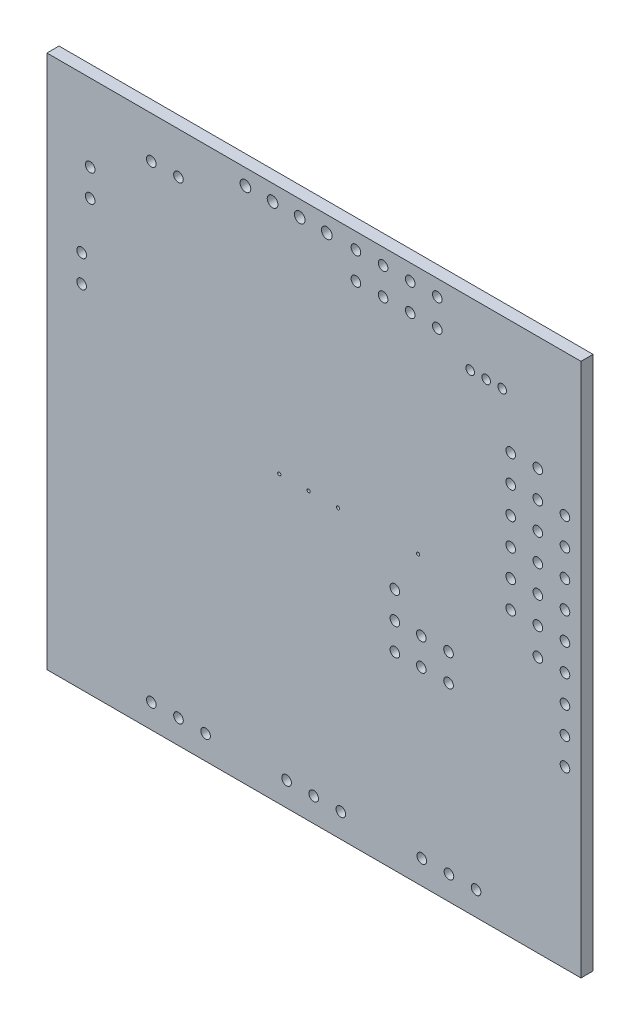
from build123d import *

# Parameters (mm, degrees)
SKETCH_1_W      = 49.99999906
SKETCH_1_H      = 49.99999906
SKETCH_1_R      = 0.4499991
SKETCH_1_R_2    = 0.3999992
SKETCH_1_R_3    = 0.499999
SKETCH_1_R_4    = 0.1499997
EXTRUDE_1_DEPTH = 1.13284


with BuildPart() as part:
    # Эскиз1 → Бобышка-Вытянуть1 (new body)
    with BuildSketch(Plane.XY.offset(1.13284)):
        with Locations((34.25000135, 36.75000143)):
            Rectangle(SKETCH_1_W, SKETCH_1_H)
        with Locations((57.75002166, 48.50003254)):
            Circle(SKETCH_1_R, mode=Mode.SUBTRACT)
        with Locations((57.75002166, 45.95002494)):
            Circle(SKETCH_1_R, mode=Mode.SUBTRACT)
        with Locations((55.21002166, 51.05004014)):
            Circle(SKETCH_1_R, mode=Mode.SUBTRACT)
        with Locations((55.21002166, 48.50003254)):
            Circle(SKETCH_1_R, mode=Mode.SUBTRACT)
        with Locations((55.21002166, 45.95002494)):
            Circle(SKETCH_1_R, mode=Mode.SUBTRACT)
        with Locations((57.75002166, 43.40001734)):
            Circle(SKETCH_1_R, mode=Mode.SUBTRACT)
        with Locations((52.67002166, 43.40001734)):
            Circle(SKETCH_1_R, mode=Mode.SUBTRACT)
        with Locations((55.21002166, 43.40001734)):
            Circle(SKETCH_1_R, mode=Mode.SUBTRACT)
        with Locations((50.37499958, 55.85000006)):
            Circle(SKETCH_1_R_2, mode=Mode.SUBTRACT)
        with Locations((51.87499912, 55.85000006)):
            Circle(SKETCH_1_R_2, mode=Mode.SUBTRACT)
        with Locations((45.79999984, 60.24999888)):
            Circle(SKETCH_1_R, mode=Mode.SUBTRACT)
        with Locations((45.79999984, 57.70999888)):
            Circle(SKETCH_1_R, mode=Mode.SUBTRACT)
        with Locations((52.67002166, 48.50003254)):
            Circle(SKETCH_1_R, mode=Mode.SUBTRACT)
        with Locations((52.67002166, 45.95002494)):
            Circle(SKETCH_1_R, mode=Mode.SUBTRACT)
        with Locations((48.87500004, 55.85000006)):
            Circle(SKETCH_1_R_2, mode=Mode.SUBTRACT)
        with Locations((52.67002166, 51.05004014)):
            Circle(SKETCH_1_R, mode=Mode.SUBTRACT)
        with Locations((57.75002166, 40.85000974)):
            Circle(SKETCH_1_R, mode=Mode.SUBTRACT)
        with Locations((57.75002166, 38.30000214)):
            Circle(SKETCH_1_R, mode=Mode.SUBTRACT)
        with Locations((55.21002166, 40.85000974)):
            Circle(SKETCH_1_R, mode=Mode.SUBTRACT)
        with Locations((55.21002166, 38.30000214)):
            Circle(SKETCH_1_R, mode=Mode.SUBTRACT)
        with Locations((57.75002166, 35.74999454)):
            Circle(SKETCH_1_R, mode=Mode.SUBTRACT)
        with Locations((57.7499988, 33.20000218)):
            Circle(SKETCH_1_R, mode=Mode.SUBTRACT)
        with Locations((57.7499988, 30.66000218)):
            Circle(SKETCH_1_R, mode=Mode.SUBTRACT)
        with Locations((57.7499988, 28.12000218)):
            Circle(SKETCH_1_R, mode=Mode.SUBTRACT)
        with Locations((52.67002166, 40.85000974)):
            Circle(SKETCH_1_R, mode=Mode.SUBTRACT)
        with Locations((55.21002166, 35.74999454)):
            Circle(SKETCH_1_R, mode=Mode.SUBTRACT)
        with Locations((52.67002166, 38.30000214)):
            Circle(SKETCH_1_R, mode=Mode.SUBTRACT)
        with Locations((46.85012474, 32.00998424)):
            Circle(SKETCH_1_R, mode=Mode.SUBTRACT)
        with Locations((46.89004846, 14.00002534)):
            Circle(SKETCH_1_R, mode=Mode.SUBTRACT)
        with Locations((49.43004846, 14.00002534)):
            Circle(SKETCH_1_R, mode=Mode.SUBTRACT)
        with Locations((46.85012474, 29.46998424)):
            Circle(SKETCH_1_R, mode=Mode.SUBTRACT)
        with Locations((44.35004846, 14.00002534)):
            Circle(SKETCH_1_R, mode=Mode.SUBTRACT)
        with Locations((40.71999984, 60.24999888)):
            Circle(SKETCH_1_R, mode=Mode.SUBTRACT)
        with Locations((43.25999984, 60.24999888)):
            Circle(SKETCH_1_R, mode=Mode.SUBTRACT)
        with Locations((32.91498116, 60.26500012)):
            Circle(SKETCH_1_R_3, mode=Mode.SUBTRACT)
        with Locations((35.45498116, 60.26500012)):
            Circle(SKETCH_1_R_3, mode=Mode.SUBTRACT)
        with Locations((40.71999984, 57.70999888)):
            Circle(SKETCH_1_R, mode=Mode.SUBTRACT)
        with Locations((43.25999984, 57.70999888)):
            Circle(SKETCH_1_R, mode=Mode.SUBTRACT)
        with Locations((38.17999984, 60.24999888)):
            Circle(SKETCH_1_R, mode=Mode.SUBTRACT)
        with Locations((38.17999984, 57.70999888)):
            Circle(SKETCH_1_R, mode=Mode.SUBTRACT)
        with Locations((27.83498116, 60.26500012)):
            Circle(SKETCH_1_R_3, mode=Mode.SUBTRACT)
        with Locations((30.37498116, 60.26500012)):
            Circle(SKETCH_1_R_3, mode=Mode.SUBTRACT)
        with Locations((19.02499878, 57.85000114)):
            Circle(SKETCH_1_R, mode=Mode.SUBTRACT)
        with Locations((21.56499878, 57.85000114)):
            Circle(SKETCH_1_R, mode=Mode.SUBTRACT)
        with Locations((13.2999988, 54.5249989)):
            Circle(SKETCH_1_R, mode=Mode.SUBTRACT)
        with Locations((13.2999988, 51.9849989)):
            Circle(SKETCH_1_R, mode=Mode.SUBTRACT)
        with Locations((12.50000548, 47.1899996)):
            Circle(SKETCH_1_R, mode=Mode.SUBTRACT)
        with Locations((12.50000548, 44.6499996)):
            Circle(SKETCH_1_R, mode=Mode.SUBTRACT)
        with Locations((43.99998566, 38.50000174)):
            Circle(SKETCH_1_R_4, mode=Mode.SUBTRACT)
        with Locations((41.82503446, 34.54998424)):
            Circle(SKETCH_1_R, mode=Mode.SUBTRACT)
        with Locations((36.50002606, 38.50000174)):
            Circle(SKETCH_1_R_4, mode=Mode.SUBTRACT)
        with Locations((41.82503446, 32.00998424)):
            Circle(SKETCH_1_R, mode=Mode.SUBTRACT)
        with Locations((44.3000892, 32.00998424)):
            Circle(SKETCH_1_R, mode=Mode.SUBTRACT)
        with Locations((44.3000892, 29.46998424)):
            Circle(SKETCH_1_R, mode=Mode.SUBTRACT)
        with Locations((41.82503446, 29.46998424)):
            Circle(SKETCH_1_R, mode=Mode.SUBTRACT)
        with Locations((36.76753886, 14.00002534)):
            Circle(SKETCH_1_R, mode=Mode.SUBTRACT)
        with Locations((33.75001886, 38.50000174)):
            Circle(SKETCH_1_R_4, mode=Mode.SUBTRACT)
        with Locations((34.22753886, 14.00002534)):
            Circle(SKETCH_1_R, mode=Mode.SUBTRACT)
        with Locations((31.00001166, 38.50000174)):
            Circle(SKETCH_1_R_4, mode=Mode.SUBTRACT)
        with Locations((19.02502926, 14.00002534)):
            Circle(SKETCH_1_R, mode=Mode.SUBTRACT)
        with Locations((24.10502926, 14.00002534)):
            Circle(SKETCH_1_R, mode=Mode.SUBTRACT)
        with Locations((31.68753886, 14.00002534)):
            Circle(SKETCH_1_R, mode=Mode.SUBTRACT)
        with Locations((21.56502926, 14.00002534)):
            Circle(SKETCH_1_R, mode=Mode.SUBTRACT)
    extrude(amount=-EXTRUDE_1_DEPTH)


solid = part.part
